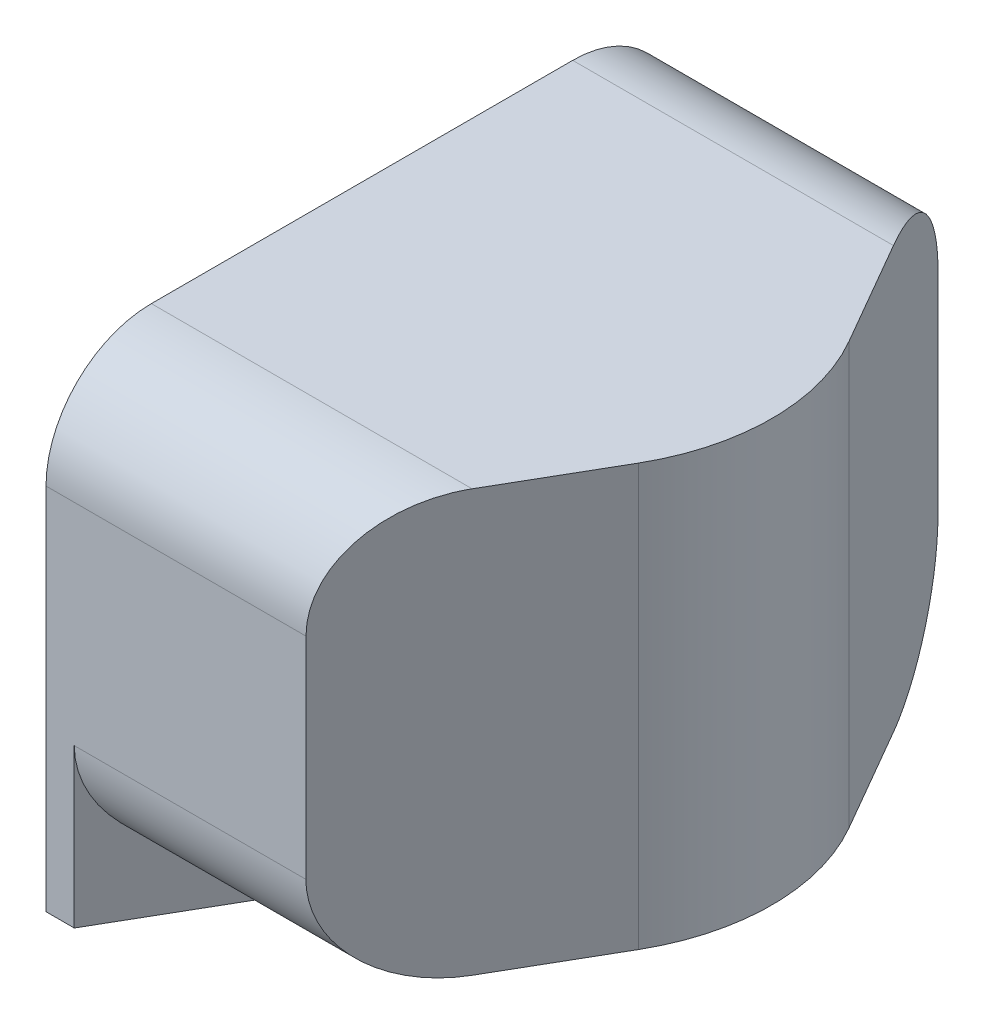
from build123d import *

# Parameters (mm, degrees)
BOSS_EXTRUDE1_START      = 23
SKETCH1_W                = 6
SKETCH1_H                = 4
BOSS_EXTRUDE1_DEPTH      = 4.2
CUT_EXTRUDE1_DEPTH       = 24.280893454
CUT_EXTRUDE1_DEPTH_BACK  = 24.280893454
BOSS_EXTRUDE3_DEPTH      = 2
BOSS_EXTRUDE3_DEPTH_BACK = 2.5
FILLET2_R                = 1


with BuildPart() as part:
    # Sketch1 → Boss-Extrude1 (new body)
    with BuildSketch(Plane(origin=(0, 0, 0), x_dir=(0, 0, -1), z_dir=(1, 0, 0)).offset(BOSS_EXTRUDE1_START)):
        Rectangle(SKETCH1_W, SKETCH1_H)
    extrude(amount=-BOSS_EXTRUDE1_DEPTH)

    # Sketch2 → Cut-Extrude1 (cut, two sides)
    with BuildSketch(Plane(origin=(0, 0, 0), x_dir=(1, 0, 0), z_dir=(0, 1, 0))) as cut_extrude1_sk:
        with BuildLine():
            Line((22.422649731, 1), (11.5, 19.918584287))
            Line((11.5, 19.918584287), (23, 19.918584287))
            Line((23, 19.918584287), (23, -19.918584287))
            Line((23, -19.918584287), (11.5, -19.918584287))
            Line((11.5, -19.918584287), (22.422649731, -1))
            ThreePointArc((22.422649731, -1), (22.690598923, 0), (22.422649731, 1))
        make_face()
    extrude(amount=CUT_EXTRUDE1_DEPTH, mode=Mode.SUBTRACT)
    extrude(cut_extrude1_sk.sketch, amount=-CUT_EXTRUDE1_DEPTH_BACK, mode=Mode.SUBTRACT)

    # Sketch5 → Boss-Extrude3 (add, two sides)
    with BuildSketch(Plane(origin=(0, 0, 0), x_dir=(1, 0, 0), z_dir=(0, 1, 0))) as boss_extrude3_sk:
        Polygon((19.067949192, -3), (20.8, 0), (19.067949192, 3), (18.8, 3), (18.8, -3), align=None)
    extrude(amount=BOSS_EXTRUDE3_DEPTH)
    extrude(boss_extrude3_sk.sketch, amount=-BOSS_EXTRUDE3_DEPTH_BACK)

    # Fillet2
    fillet2_edges = [part.edges().sort_by_distance(p)[0] for p in [
        (20.167949192, -2, 3),
        (20.167949192, -2, -3),
        (20.033974596, 2, 3),
        (20.033974596, 2, -3),
    ]]
    fillet(fillet2_edges, radius=FILLET2_R)


solid = part.part
